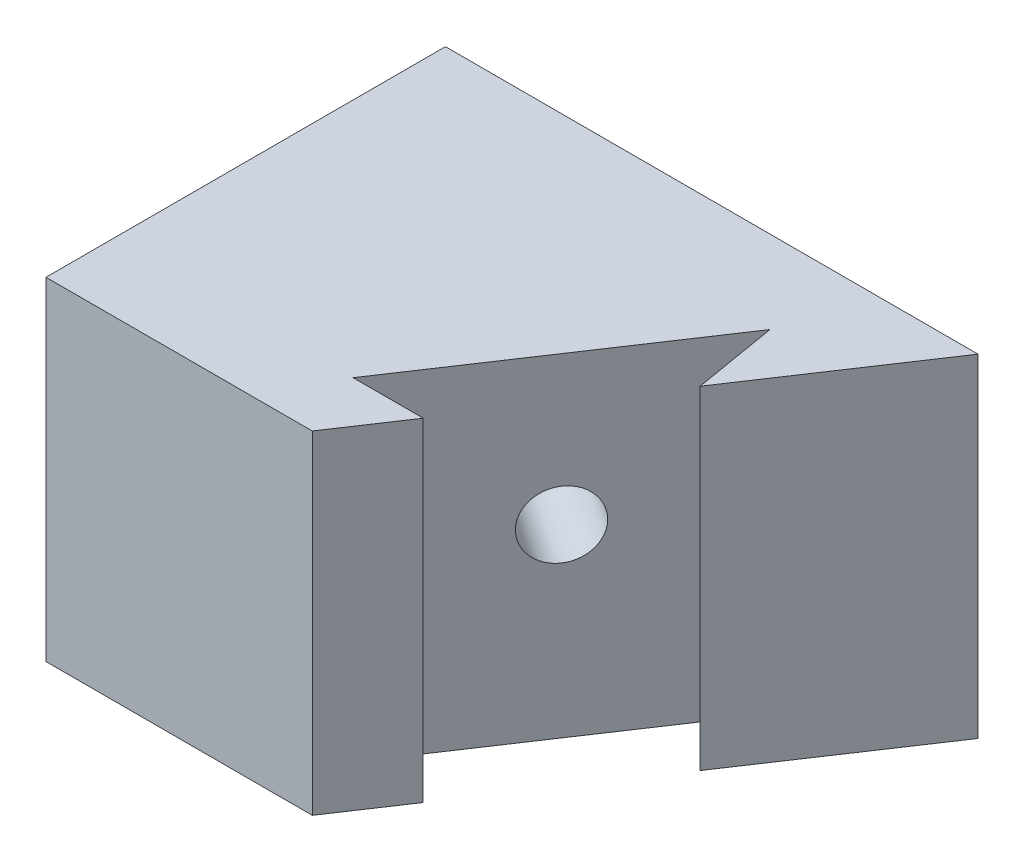
from build123d import *

# Parameters (mm, degrees)
SKETCH2_W           = 80
SKETCH2_H           = 60
BOSS_EXTRUDE2_DEPTH = 50
CUT_EXTRUDE1_DEPTH  = 51
CUT_EXTRUDE3_DEPTH  = 51
SKETCH10_R          = 5
CUT_EXTRUDE4_DEPTH  = 58.795911827


with BuildPart() as part:
    # Sketch2 → Boss-Extrude2 (new body)
    with BuildSketch(Plane(origin=(0, 0, 0), x_dir=(1, 0, 0), z_dir=(0, 1, 0))):
        Rectangle(SKETCH2_W, SKETCH2_H)
    extrude(amount=BOSS_EXTRUDE2_DEPTH)

    # Sketch4 → Cut-Extrude1 (cut, through all)
    with BuildSketch(Plane(origin=(0, 50, 0), x_dir=(1, 0, 0), z_dir=(0, 1, 0))):
        Polygon((0, -30), (40, 30), (40, -30), align=None)
    extrude(amount=-CUT_EXTRUDE1_DEPTH, mode=Mode.SUBTRACT)

    # Sketch9 → Cut-Extrude3 (cut, through all)
    with BuildSketch(Plane(origin=(0, 50, 0), x_dir=(1, 0, 0), z_dir=(0, 1, 0))):
        Polygon((23.307672553, 4.96150883), (21.177929754, 17.573832829), (-3.871292132, -20), (6.666666667, -20), align=None)
    extrude(amount=-CUT_EXTRUDE3_DEPTH, mode=Mode.SUBTRACT)

    # Sketch10 → Cut-Extrude4 (cut, through all)
    with BuildSketch(Plane(origin=(6.550643909, 0, 4.367095939), x_dir=(0.554700196, 0, -0.832050294), z_dir=(0.832050294, 0, 0.554700196))):
        with Locations((3.790651088, 27.7575331)):
            Circle(SKETCH10_R)
    extrude(amount=-CUT_EXTRUDE4_DEPTH, mode=Mode.SUBTRACT)


solid = part.part
